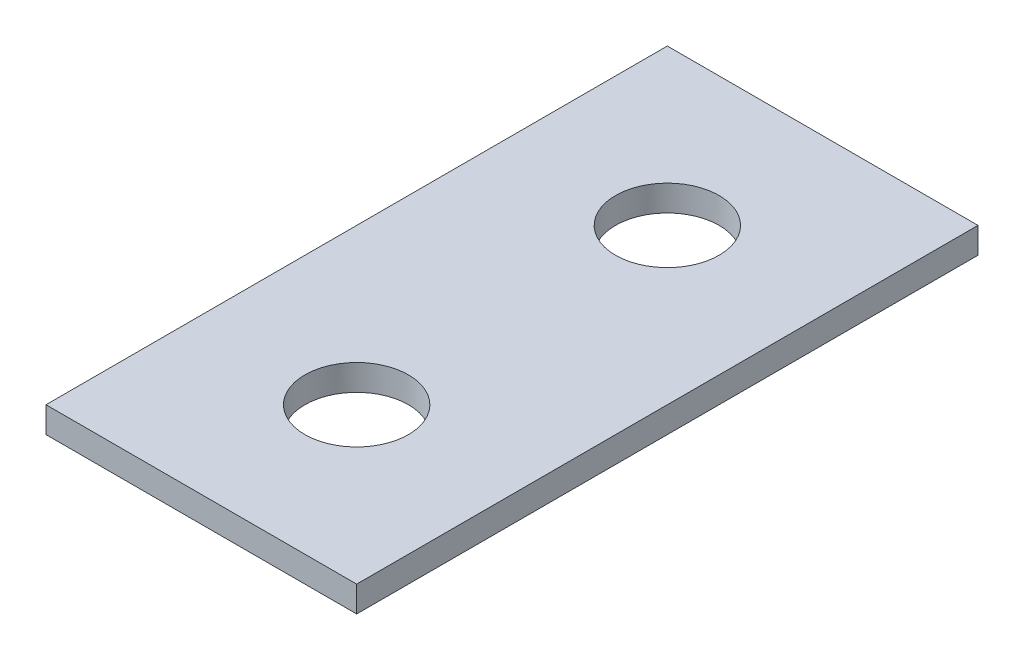
from build123d import *

# Parameters (mm, degrees)
SKETCH1_W                  = 76.2
SKETCH1_H                  = 152.4
BOSS_EXTRUDE1_DEPTH        = 6.35
F_1_1_DIAMETER_HOLE1_D     = 25.4
F_1_1_DIAMETER_HOLE1_DEPTH = 20.574
F_1_1_DIAMETER_HOLE1_TIP   = 7.630929862


with BuildPart() as part:
    # Sketch1 → Boss-Extrude1 (new body)
    with BuildSketch(Plane(origin=(0, 0, 0), x_dir=(1, 0, 0), z_dir=(0, 1, 0))):
        with Locations((38.1, 76.2)):
            Rectangle(SKETCH1_W, SKETCH1_H)
    extrude(amount=BOSS_EXTRUDE1_DEPTH)

    # 1 (1) Diameter Hole1
    with Locations(Plane(origin=(0, 6.35, 0), x_dir=(-1, 0, 0), z_dir=(0, 1, 0))):
        with Locations((-38.1, -38.1), (-38.1, -114.3)):
            Hole(F_1_1_DIAMETER_HOLE1_D / 2, depth=F_1_1_DIAMETER_HOLE1_DEPTH)
            with Locations((0, 0, -(F_1_1_DIAMETER_HOLE1_DEPTH + F_1_1_DIAMETER_HOLE1_TIP / 2))):  # 118° drill point
                Cone(0, F_1_1_DIAMETER_HOLE1_D / 2, F_1_1_DIAMETER_HOLE1_TIP, mode=Mode.SUBTRACT)


solid = part.part
